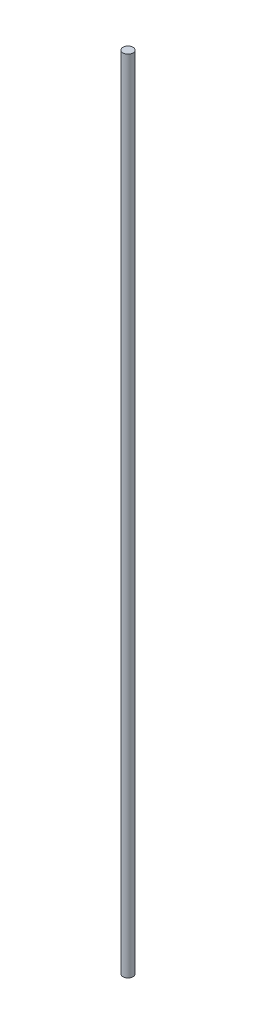
from build123d import *

# Parameters (mm, degrees)
SKETCH1_R           = 1.5875
BOSS_EXTRUDE1_DEPTH = 254


with BuildPart() as part:
    # Sketch1 → Boss-Extrude1 (new body)
    with BuildSketch(Plane(origin=(0, 0, 0), x_dir=(1, 0, 0), z_dir=(0, 1, 0))):
        Circle(SKETCH1_R)
    extrude(amount=BOSS_EXTRUDE1_DEPTH)


solid = part.part
